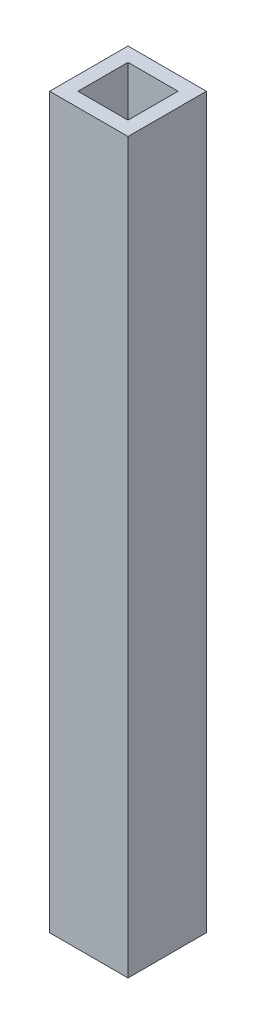
from build123d import *

# Parameters (mm, degrees)
SKETCH1_W           = 11.938
SKETCH1_H           = 11.938
BOSS_EXTRUDE1_DEPTH = 213.106
SKETCH2_R           = 3.68046
BOSS_EXTRUDE2_DEPTH = 22.225
SKETCH4_W           = 4.572
SKETCH4_H           = 4.572
BOSS_EXTRUDE4_DEPTH = 15.24
SKETCH5_R           = 13.051144527
CUT_EXTRUDE1_DEPTH  = 139.573
SKETCH6_W           = 7.62
SKETCH6_H           = 7.62
CUT_EXTRUDE2_DEPTH  = 12.7
SKETCH3_R           = 4.0005
CUT_EXTRUDE4_DEPTH  = 14.2875


with BuildPart() as part:
    # Sketch1 → Boss-Extrude1 (new body)
    with BuildSketch(Plane(origin=(0, 0, 0), x_dir=(1, 0, 0), z_dir=(0, 1, 0))):
        Rectangle(SKETCH1_W, SKETCH1_H)
    extrude(amount=BOSS_EXTRUDE1_DEPTH)

    # Sketch2 → Boss-Extrude2 (add)
    with BuildSketch(Plane(origin=(0, 213.106, 0), x_dir=(1, 0, 0), z_dir=(0, 1, 0))):
        Circle(SKETCH2_R)
    extrude(amount=BOSS_EXTRUDE2_DEPTH)

    # Sketch4 → Boss-Extrude4 (add)
    with BuildSketch(Plane(origin=(0, 235.331, 0), x_dir=(1, 0, 0), z_dir=(0, 1, 0))):
        Rectangle(SKETCH4_W, SKETCH4_H)
    extrude(amount=BOSS_EXTRUDE4_DEPTH)

    # Sketch5 → Cut-Extrude1 (cut)
    with BuildSketch(Plane(origin=(0, 250.571, 0), x_dir=(1, 0, 0), z_dir=(0, 1, 0))):
        Circle(SKETCH5_R)
    extrude(amount=-CUT_EXTRUDE1_DEPTH, mode=Mode.SUBTRACT)

    # Sketch6 → Cut-Extrude2 (cut)
    with BuildSketch(Plane(origin=(0, 110.998, 0), x_dir=(1, 0, 0), z_dir=(0, 1, 0))):
        Rectangle(SKETCH6_W, SKETCH6_H)
    extrude(amount=-CUT_EXTRUDE2_DEPTH, mode=Mode.SUBTRACT)

    # Sketch3 → Cut-Extrude4 (cut)
    with BuildSketch(Plane(origin=(0, 0, 0), x_dir=(-1, 0, 0), z_dir=(0, -1, 0))):
        Circle(SKETCH3_R)
    extrude(amount=-CUT_EXTRUDE4_DEPTH, mode=Mode.SUBTRACT)


solid = part.part
